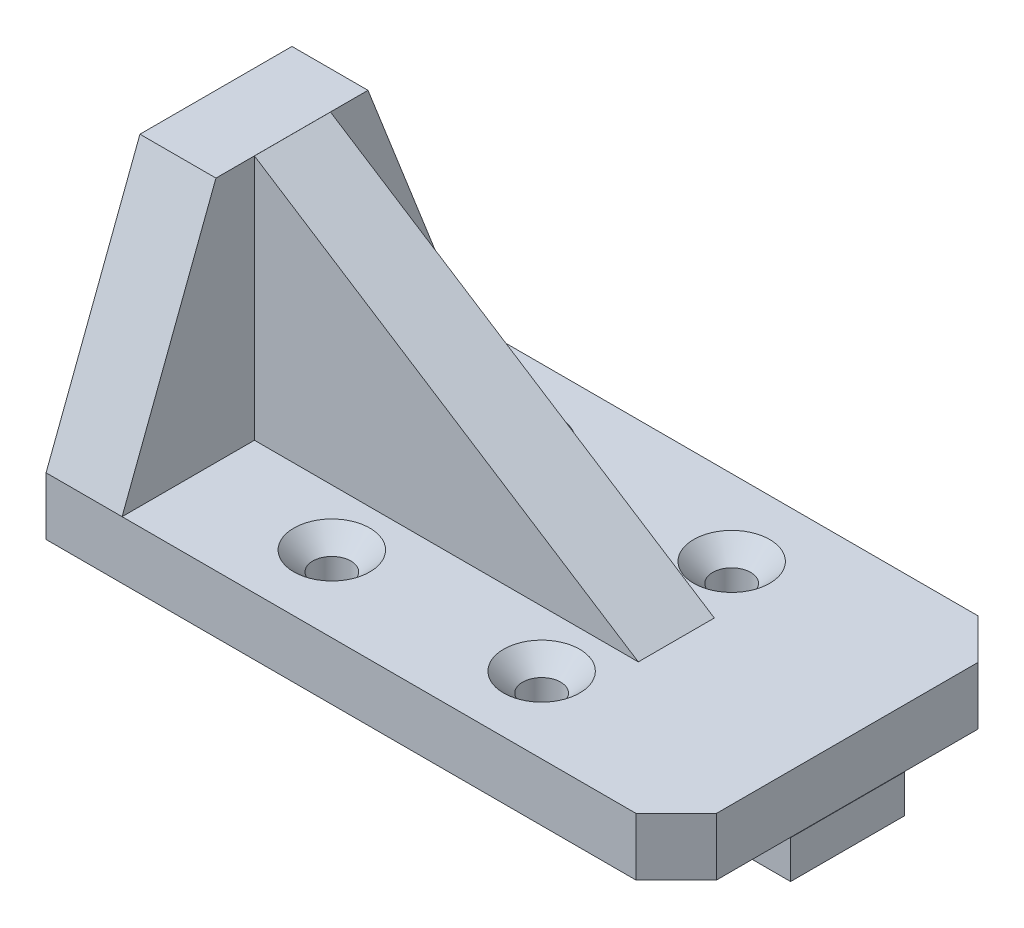
from build123d import *

# Parameters (mm, degrees)
SKETCH1_R           = 3.175
BOSS_EXTRUDE4_DEPTH = 9.652
BOSS_EXTRUDE5_START = -1.778
SKETCH2_W           = 19.05
SKETCH2_H           = 6.35
BOSS_EXTRUDE5_DEPTH = 105.33369205
BOSS_EXTRUDE6_START = 21.082
BOSS_EXTRUDE6_DEPTH = 12.7
BOSS_EXTRUDE7_START = -1.778
BOSS_EXTRUDE7_DEPTH = 12.7


with BuildPart() as part:
    # Sketch1 → Boss-Extrude4 (new body)
    with BuildSketch(Plane(origin=(0, 0, 0), x_dir=(1, 0, 0), z_dir=(0, 1, 0))):
        Polygon((96.761507042, 1.255721831), (-1.790492958, 1.255721831), (-1.790492958, -55.894278169), (96.761507042, -55.894278169), (103.496699133, -49.159086078), (103.496699133, -5.47947026), align=None)
        with Locations((33.261507042, -43.194278169)):
            Circle(SKETCH1_R, mode=Mode.SUBTRACT)
        with Locations((68.313507042, -43.194278169)):
            Circle(SKETCH1_R, mode=Mode.SUBTRACT)
        with Locations((33.261507042, -11.444278169)):
            Circle(SKETCH1_R, mode=Mode.SUBTRACT)
        with Locations((68.313507042, -11.444278169)):
            Circle(SKETCH1_R, mode=Mode.SUBTRACT)
    extrude(amount=-BOSS_EXTRUDE4_DEPTH)

    # Cut-Extrude4 cone 1 section (through the dimple's axis) → Cut-Extrude4 (revolve, cut)
    with BuildSketch(Plane(origin=(33.261507042, 0, 11.444278169), x_dir=(0, 0, 1), z_dir=(1, 0, 0))):
        Polygon((0, 0), (6.35, 0), (0, 6.35), align=None)
    revolve(axis=Axis((33.261507042, 0, 11.444278169), (0, -1, 0)), mode=Mode.SUBTRACT)

    # Cut-Extrude4 cone 2 section (through the dimple's axis) → Cut-Extrude4 cone 2 (revolve, cut)
    with BuildSketch(Plane(origin=(68.313507042, 0, 11.444278169), x_dir=(0, 0, 1), z_dir=(1, 0, 0))):
        Polygon((0, 0), (6.35, 0), (0, 6.35), align=None)
    revolve(axis=Axis((68.313507042, 0, 11.444278169), (0, -1, 0)), mode=Mode.SUBTRACT)

    # Cut-Extrude4 cone 3 section (through the dimple's axis) → Cut-Extrude4 cone 3 (revolve, cut)
    with BuildSketch(Plane(origin=(33.261507042, 0, 43.194278169), x_dir=(0, 0, 1), z_dir=(1, 0, 0))):
        Polygon((0, 0), (6.35, 0), (0, 6.35), align=None)
    revolve(axis=Axis((33.261507042, 0, 43.194278169), (0, -1, 0)), mode=Mode.SUBTRACT)

    # Cut-Extrude4 cone 4 section (through the dimple's axis) → Cut-Extrude4 cone 4 (revolve, cut)
    with BuildSketch(Plane(origin=(68.313507042, 0, 43.194278169), x_dir=(0, 0, 1), z_dir=(1, 0, 0))):
        Polygon((0, 0), (6.35, 0), (0, 6.35), align=None)
    revolve(axis=Axis((68.313507042, 0, 43.194278169), (0, -1, 0)), mode=Mode.SUBTRACT)

    # Sketch2 → Boss-Extrude5 (add)
    with BuildSketch(Plane(origin=(0, 0, 0), x_dir=(0, 0, -1), z_dir=(1, 0, 0)).offset(BOSS_EXTRUDE5_START)):
        with Locations((-27.319278169, -12.827)):
            Rectangle(SKETCH2_W, SKETCH2_H)
    extrude(amount=BOSS_EXTRUDE5_DEPTH)

    # Sketch4 → Boss-Extrude6 (add)
    with BuildSketch(Plane.XY.offset(BOSS_EXTRUDE6_START)):
        Polygon((10.909507042, 0), (10.909507042, 41.148), (75.048699133, 0), align=None)
    extrude(amount=BOSS_EXTRUDE6_DEPTH)

    # Sketch5 → Boss-Extrude7 (add)
    with BuildSketch(Plane(origin=(0, 0, 0), x_dir=(0, 0, -1), z_dir=(1, 0, 0)).offset(BOSS_EXTRUDE7_START)):
        Polygon((-14.81428613, 41.148), (-40.21428613, 41.148), (-55.894278169, 0), (1.255721831, 0), align=None)
    extrude(amount=BOSS_EXTRUDE7_DEPTH)


solid = part.part
